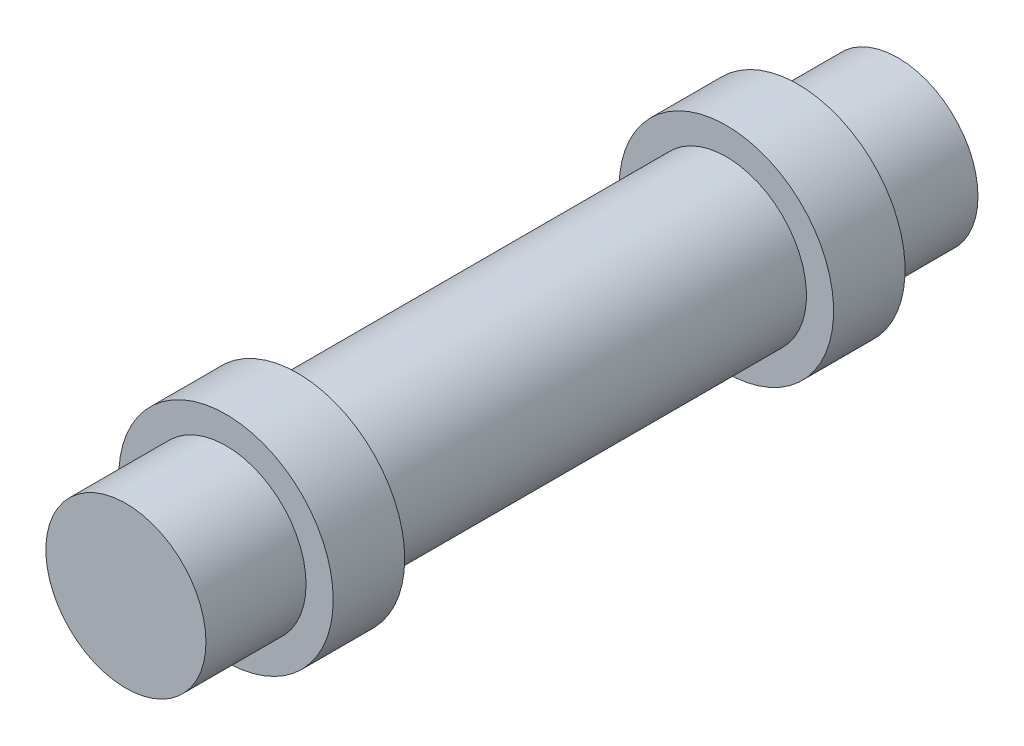
from build123d import *

# Parameters (mm, degrees)
CROQUIS1_R              = 5.6
SALIENTE_EXTRUIR1_DEPTH = 54
CROQUIS2_R              = 7.5
SALIENTE_EXTRUIR2_DEPTH = 5
CROQUIS3_R              = 7.5
SALIENTE_EXTRUIR3_DEPTH = 5


with BuildPart() as part:
    # Croquis1 → Saliente-Extruir1 (new body)
    with BuildSketch(Plane.XY):
        Circle(CROQUIS1_R)
    extrude(amount=SALIENTE_EXTRUIR1_DEPTH)

    # Croquis2 → Saliente-Extruir2 (add)
    with BuildSketch(Plane.XY.offset(47)):
        Circle(CROQUIS2_R)
    extrude(amount=-SALIENTE_EXTRUIR2_DEPTH)

    # Croquis3 → Saliente-Extruir3 (add)
    with BuildSketch(Plane(origin=(0, 0, 7), x_dir=(-1, 0, 0), z_dir=(0, 0, -1))):
        Circle(CROQUIS3_R)
    extrude(amount=-SALIENTE_EXTRUIR3_DEPTH)


solid = part.part
